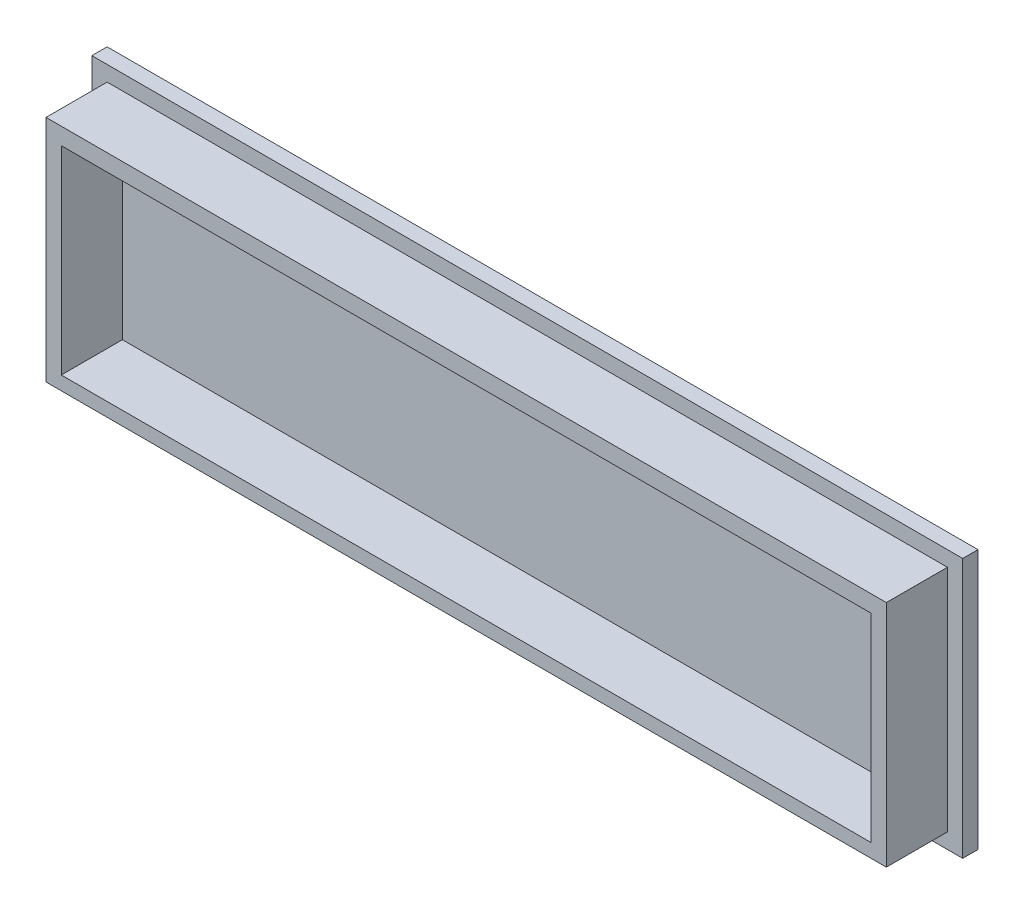
from build123d import *

# Parameters (mm, degrees)
SKETCH1_W           = 285
SKETCH1_H           = 85
BOSS_EXTRUDE1_DEPTH = 5
SKETCH2_W           = 275
SKETCH2_H           = 75
BOSS_EXTRUDE2_DEPTH = 20
SKETCH3_W           = 265
SKETCH3_H           = 65
CUT_EXTRUDE1_DEPTH  = 20


with BuildPart() as part:
    # Sketch1 → Boss-Extrude1 (new body)
    with BuildSketch(Plane.XY):
        with Locations((3.487762238, -31.988636364)):
            Rectangle(SKETCH1_W, SKETCH1_H)
    extrude(amount=BOSS_EXTRUDE1_DEPTH)

    # Sketch2 → Boss-Extrude2 (add)
    with BuildSketch(Plane.XY.offset(5)):
        with Locations((3.487762238, -31.988636364)):
            Rectangle(SKETCH2_W, SKETCH2_H)
    extrude(amount=BOSS_EXTRUDE2_DEPTH)

    # Sketch3 → Cut-Extrude1 (cut)
    with BuildSketch(Plane.XY.offset(25)):
        with Locations((3.487762238, -32.5)):
            Rectangle(SKETCH3_W, SKETCH3_H)
    extrude(amount=-CUT_EXTRUDE1_DEPTH, mode=Mode.SUBTRACT)


solid = part.part
